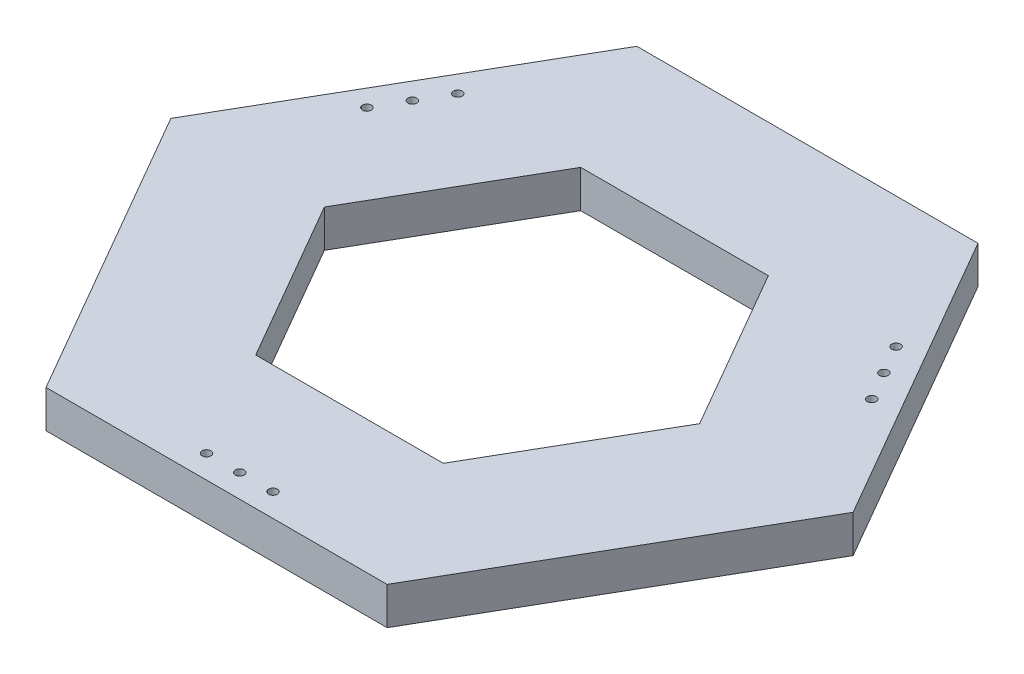
from build123d import *

# Parameters (mm, degrees)
SALIENTE_EXTRUIR1_DEPTH = 25.4
CROQUIS2_R              = 3
CORTAR_EXTRUIR2_DEPTH   = 26.4


with BuildPart() as part:
    # Croquis1 → Saliente-Extruir1 (new body)
    with BuildSketch(Plane(origin=(0, 0, 0), x_dir=(1, 0, 0), z_dir=(0, 1, 0))):
        Polygon((115.470053838, -200), (230.940107676, 0), (115.470053838, 200), (-115.470053838, 200), (-230.940107676, 0), (-115.470053838, -200), align=None)
        Polygon((127.017059222, 0), (63.508529611, 110), (-63.508529611, 110), (-127.017059222, 0), (-63.508529611, -110), (63.508529611, -110), align=None, mode=Mode.SUBTRACT)
    extrude(amount=SALIENTE_EXTRUIR1_DEPTH)

    # Croquis2 → Cortar-Extruir2 (cut, through all)
    with BuildSketch(Plane(origin=(0, 25.4, 0), x_dir=(1, 0, 0), z_dir=(0, 1, 0))):
        with Locations((0, -184.3)):
            Circle(CROQUIS2_R)
        with Locations((-22.5, -184.3)):
            Circle(CROQUIS2_R)
        with Locations((22.5, -184.3)):
            Circle(CROQUIS2_R)
        with Locations((-148.358481917, 111.635571585)):
            Circle(CROQUIS2_R)
        with Locations((-159.608481917, 92.15)):
            Circle(CROQUIS2_R)
        with Locations((-170.858481917, 72.664428415)):
            Circle(CROQUIS2_R)
        with Locations((170.858481917, 72.664428415)):
            Circle(CROQUIS2_R)
        with Locations((159.608481917, 92.15)):
            Circle(CROQUIS2_R)
        with Locations((148.358481917, 111.635571585)):
            Circle(CROQUIS2_R)
    extrude(amount=-CORTAR_EXTRUIR2_DEPTH, mode=Mode.SUBTRACT)


solid = part.part
